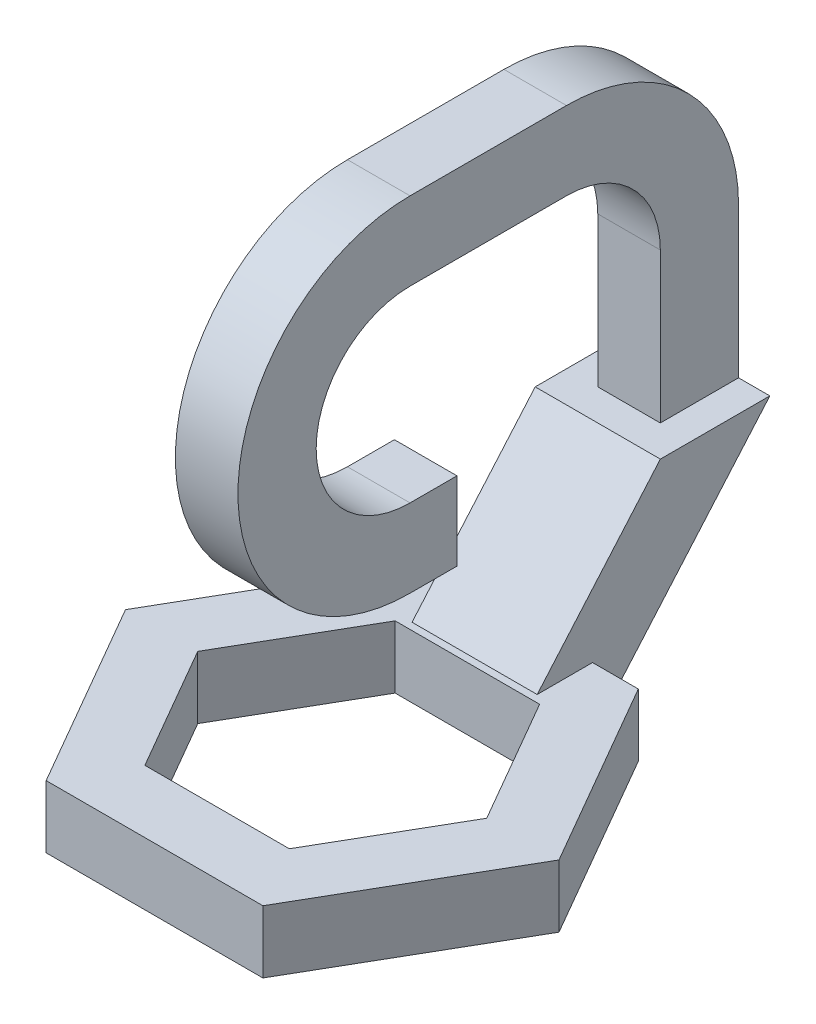
from build123d import *

# Parameters (mm, degrees)
SALIENTE_EXTRUIR1_DEPTH = 80
SALIENTE_EXTRUIR2_DEPTH = 80
SALIENTE_EXTRUIR4_DEPTH = 40


with BuildPart() as part:
    # Croquis1 → Saliente-Extruir1 (new body)
    with BuildSketch(Plane(origin=(0, 0, 0), x_dir=(1, 0, 0), z_dir=(0, 1, 0))):
        Polygon((-138.55, 239.975639389), (-277.1, 0), (-138.55, -239.975639389), (138.55, -239.975639389), (277.1, 0), (138.55, 239.975639389), align=None)
        Polygon((-92.361978465, 159.975639389), (-184.72395693, 0), (-92.361978465, -159.975639389), (92.361978465, -159.975639389), (184.72395693, 0), (92.361978465, 159.975639389), align=None, mode=Mode.SUBTRACT)
    extrude(amount=SALIENTE_EXTRUIR1_DEPTH)

    # Croquis2 → Saliente-Extruir2 (add, symmetric)
    with BuildSketch(Plane(origin=(0, 0, 0), x_dir=(0, 0, -1), z_dir=(1, 0, 0))):
        Polygon((239.975639389, 0), (466.675639389, 261.9), (326.675639389, 261.9), (169.223443894, 80), (169.223443894, 0), align=None)
    extrude(amount=SALIENTE_EXTRUIR2_DEPTH, both=True)

    # Croquis3 → Saliente-Extruir4 (add, symmetric)
    with BuildSketch(Plane(origin=(0, 0, 0), x_dir=(0, 0, -1), z_dir=(1, 0, 0))):
        with BuildLine():
            Line((366.675639389, 453.4), (366.675639389, 261.9))
            Line((366.675639389, 261.9), (466.675639389, 261.9))
            Line((466.675639389, 261.9), (466.675639389, 453.4))
            ThreePointArc((466.675639389, 453.4), (402.23913125, 608.963491861), (246.675639389, 673.4))
            Line((246.675639389, 673.4), (46.675639389, 673.4))
            ThreePointArc((46.675639389, 673.4), (-173.324360611, 453.4), (46.675639389, 233.4))
            Line((46.675639389, 233.4), (106.675639389, 233.4))
            Line((106.675639389, 233.4), (106.675639389, 333.4))
            Line((106.675639389, 333.4), (46.675639389, 333.4))
            ThreePointArc((46.675639389, 333.4), (-73.324360611, 453.4), (46.675639389, 573.4))
            Line((46.675639389, 573.4), (246.675639389, 573.4))
            ThreePointArc((246.675639389, 573.4), (331.528453131, 538.252813742), (366.675639389, 453.4))
        make_face()
    extrude(amount=SALIENTE_EXTRUIR4_DEPTH, both=True)


solid = part.part
